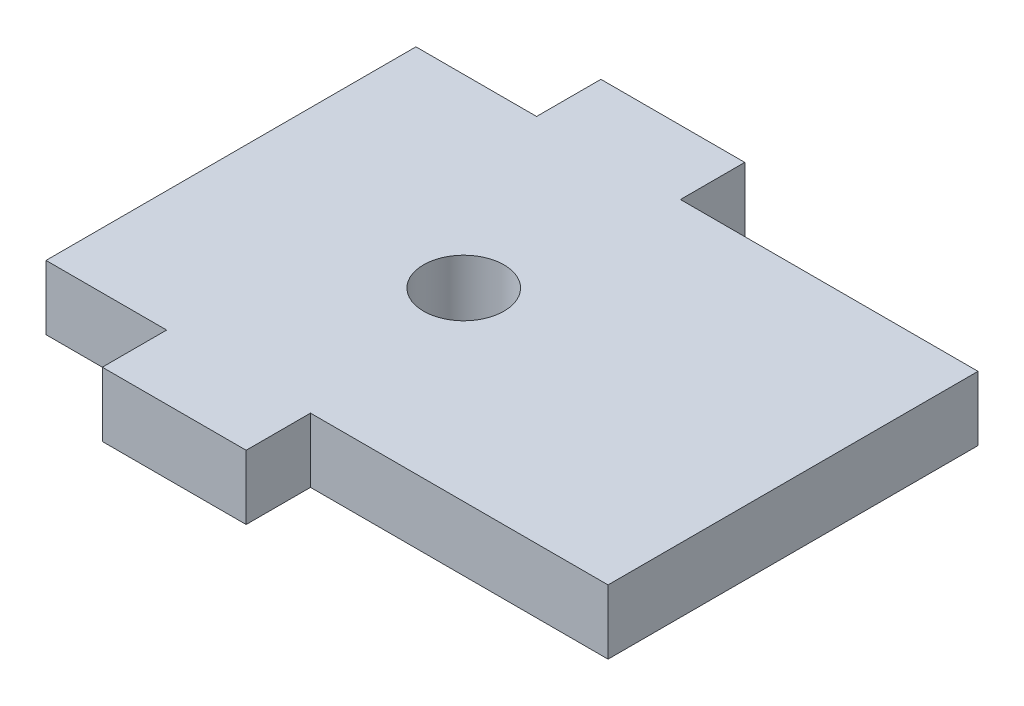
from build123d import *

# Parameters (mm, degrees)
SKETCH1_W                   = 30.408879848
SKETCH1_H                   = 29.21
SKETCH1_W_2                 = 11.358879848
SKETCH1_H_2                 = 5.08
BOSS_EXTRUDE1_DEPTH         = 5.08
F_1_4_0_25_DIAMETER_HOLE1_D = 6.35
SKETCH5_W                   = 13.97
SKETCH5_H                   = 29.21
BOSS_EXTRUDE2_DEPTH         = 5.08


with BuildPart() as part:
    # Sketch1 → Boss-Extrude1 (new body)
    with BuildSketch(Plane(origin=(0, 0, 0), x_dir=(1, 0, 0), z_dir=(0, 1, 0))):
        Rectangle(SKETCH1_W, SKETCH1_H)
        with Locations((0, 17.145)):
            Rectangle(SKETCH1_W_2, SKETCH1_H_2)
        with Locations((0, -17.145)):
            Rectangle(SKETCH1_W_2, SKETCH1_H_2)
    extrude(amount=BOSS_EXTRUDE1_DEPTH)

    # 1/4 (0.25) Diameter Hole1 (through all)
    with Locations(Plane(origin=(0, 5.08, 0), x_dir=(1, 0, 0), z_dir=(0, 1, 0))):
        with Locations((3.175, 0)):
            Hole(F_1_4_0_25_DIAMETER_HOLE1_D / 2)

    # Sketch5 → Boss-Extrude2 (add)
    with BuildSketch(Plane(origin=(0, 5.08, 0), x_dir=(1, 0, 0), z_dir=(0, 1, 0))):
        with Locations((22.189439924, 0)):
            Rectangle(SKETCH5_W, SKETCH5_H)
    extrude(amount=-BOSS_EXTRUDE2_DEPTH)


solid = part.part
